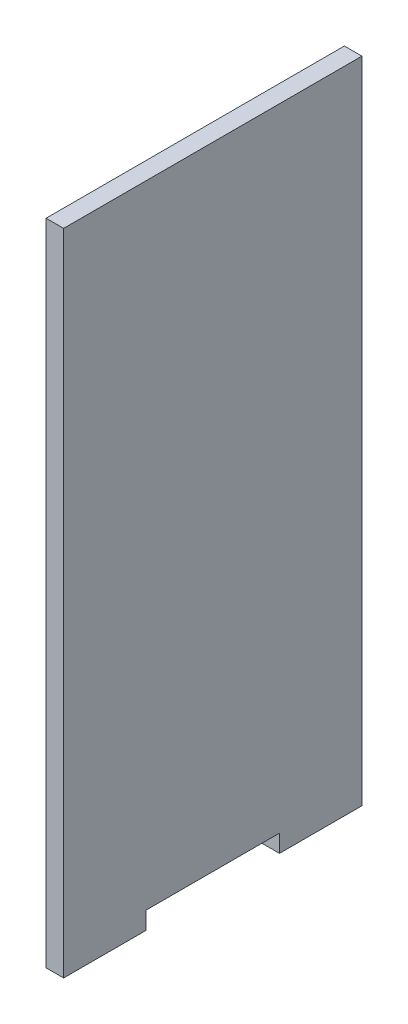
from build123d import *

# Parameters (mm, degrees)
BOSS_EXTRUDE1_DEPTH = 5


with BuildPart() as part:
    # Sketch1 → Boss-Extrude1 (new body)
    with BuildSketch(Plane(origin=(0, 0, 0), x_dir=(0, 0, -1), z_dir=(1, 0, 0))):
        Polygon((-42.5, 180), (42.5, 180), (42.5, 0), (42.5, -5), (19, -5), (19, 0), (-19, 0), (-19, -5), (-42.5, -5), (-42.5, 0), align=None)
    extrude(amount=BOSS_EXTRUDE1_DEPTH)


solid = part.part
